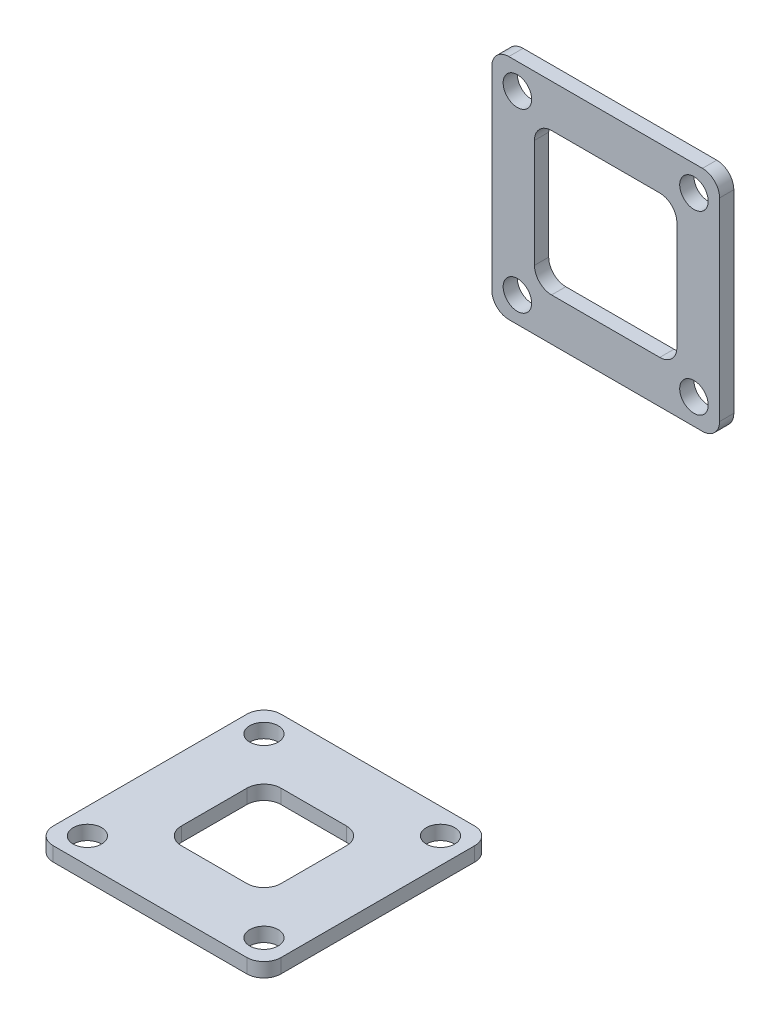
from build123d import *

# Parameters (mm, degrees)
SKETCH1_R           = 3.175
TOP_FLANGE_DEPTH    = 3.175
SKETCH2_R           = 3.175
BOTTOM_FLANGE_DEPTH = 3.175


with BuildPart() as part:
    # Sketch1 → Top-Flange (new body)
    with BuildSketch(Plane.XY):
        with BuildLine():
            Line((-21.59, 101.6), (21.59, 101.6))
            ThreePointArc((21.59, 101.6), (24.284076836, 100.484076836), (25.4, 97.79))
            Line((25.4, 97.79), (25.4, 54.61))
            ThreePointArc((25.4, 54.61), (24.284076836, 51.915923164), (21.59, 50.8))
            Line((21.59, 50.8), (-21.59, 50.8))
            ThreePointArc((-21.59, 50.8), (-24.284076836, 51.915923164), (-25.4, 54.61))
            Line((-25.4, 54.61), (-25.4, 97.79))
            ThreePointArc((-25.4, 97.79), (-24.284076836, 100.484076836), (-21.59, 101.6))
        make_face()
        with Locations((-19.685, 95.885)):
            Circle(SKETCH1_R, mode=Mode.SUBTRACT)
        with Locations((19.685, 95.885)):
            Circle(SKETCH1_R, mode=Mode.SUBTRACT)
        with Locations((-19.685, 56.515)):
            Circle(SKETCH1_R, mode=Mode.SUBTRACT)
        with Locations((19.685, 56.515)):
            Circle(SKETCH1_R, mode=Mode.SUBTRACT)
        with BuildLine():
            Line((-12.065, 92.075), (12.065, 92.075))
            ThreePointArc((12.065, 92.075), (14.759076836, 90.959076836), (15.875, 88.265))
            Line((15.875, 88.265), (15.875, 64.135))
            ThreePointArc((15.875, 64.135), (14.759076836, 61.440923164), (12.065, 60.325))
            Line((12.065, 60.325), (-12.065, 60.325))
            ThreePointArc((-12.065, 60.325), (-14.759076836, 61.440923164), (-15.875, 64.135))
            Line((-15.875, 64.135), (-15.875, 88.265))
            ThreePointArc((-15.875, 88.265), (-14.759076836, 90.959076836), (-12.065, 92.075))
        make_face(mode=Mode.SUBTRACT)
    extrude(amount=-TOP_FLANGE_DEPTH)


with BuildPart() as body_2:
    # Sketch2 → Bottom-Flange (new body)
    with BuildSketch(Plane(origin=(0, 0, 0), x_dir=(1, 0, 0), z_dir=(0, 1, 0))):
        with BuildLine():
            Line((-21.59, -50.8), (21.59, -50.8))
            ThreePointArc((21.59, -50.8), (24.284076836, -51.915923164), (25.4, -54.61))
            Line((25.4, -54.61), (25.4, -97.79))
            ThreePointArc((25.4, -97.79), (24.284076836, -100.484076836), (21.59, -101.6))
            Line((21.59, -101.6), (-21.59, -101.6))
            ThreePointArc((-21.59, -101.6), (-24.284076836, -100.484076836), (-25.4, -97.79))
            Line((-25.4, -97.79), (-25.4, -54.61))
            ThreePointArc((-25.4, -54.61), (-24.284076836, -51.915923164), (-21.59, -50.8))
        make_face()
        with Locations(Location((-19.685, -56.515, 0), (0, 0, 270))):  # turned: the seam where the file's is
            Circle(SKETCH2_R, mode=Mode.SUBTRACT)
        with Locations(Location((19.685, -56.515, 0), (0, 0, 270))):  # turned: the seam where the file's is
            Circle(SKETCH2_R, mode=Mode.SUBTRACT)
        with Locations(Location((-19.685, -95.885, 0), (0, 0, 270))):  # turned: the seam where the file's is
            Circle(SKETCH2_R, mode=Mode.SUBTRACT)
        with Locations(Location((19.685, -95.885, 0), (0, 0, 270))):  # turned: the seam where the file's is
            Circle(SKETCH2_R, mode=Mode.SUBTRACT)
        with BuildLine():
            Line((-7.3025, -65.0875), (7.3025, -65.0875))
            ThreePointArc((7.3025, -65.0875), (9.996576836, -66.203423164), (11.1125, -68.8975))
            Line((11.1125, -68.8975), (11.1125, -83.5025))
            ThreePointArc((11.1125, -83.5025), (9.996576836, -86.196576836), (7.3025, -87.3125))
            Line((7.3025, -87.3125), (-7.3025, -87.3125))
            ThreePointArc((-7.3025, -87.3125), (-9.996576836, -86.196576836), (-11.1125, -83.5025))
            Line((-11.1125, -83.5025), (-11.1125, -68.8975))
            ThreePointArc((-11.1125, -68.8975), (-9.996576836, -66.203423164), (-7.3025, -65.0875))
        make_face(mode=Mode.SUBTRACT)
    extrude(amount=-BOTTOM_FLANGE_DEPTH)


solid = Compound([part.part, body_2.part])
